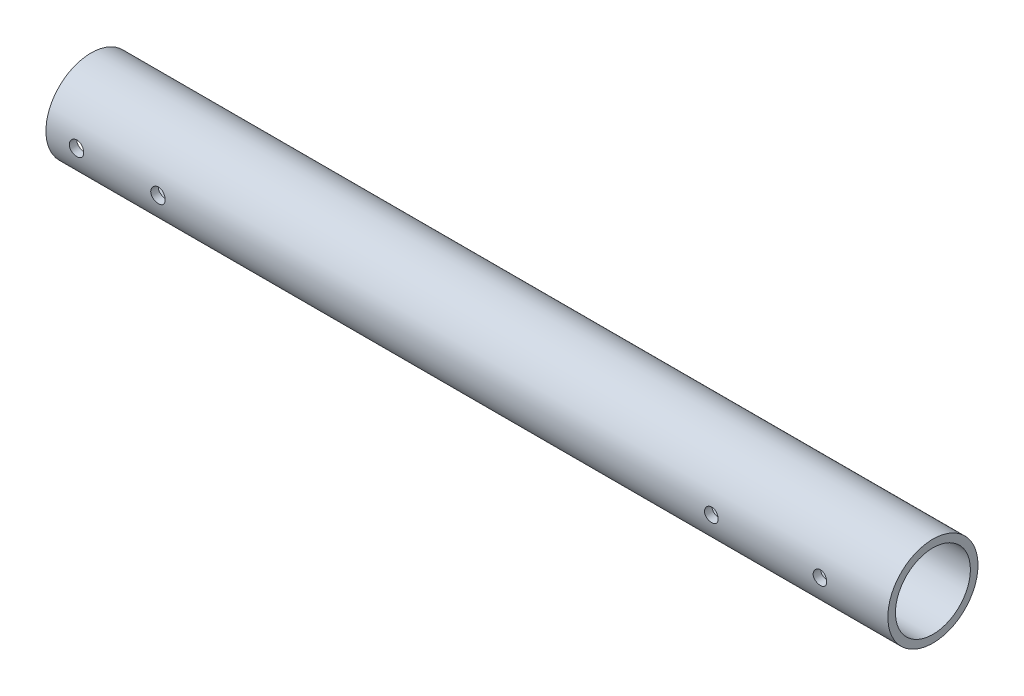
from build123d import *

# Parameters (mm, degrees)
BOSS_EXTRUDE1_DEPTH      = 196.85
BOSS_EXTRUDE1_DEPTH_BACK = 196.85
SKETCH1_R                = 21.082
SKETCH1_R_2              = 17.526
CUT_EXTRUDE1_DEPTH       = 200.095012363
CUT_EXTRUDE1_DEPTH_BACK  = 200.095012363
SKETCH2_R                = 3.3782
SKETCH3_R                = 3.175
CUT_EXTRUDE2_DEPTH       = 200.095012483


with BuildPart() as part:
    # Sketch1 → Boss-Extrude1 (new, two sides: drawn at the far end of the back side and taken through both)
    with BuildSketch(Plane(origin=(0, 0, 0), x_dir=(0, 0, -1), z_dir=(1, 0, 0)).offset(-BOSS_EXTRUDE1_DEPTH_BACK)):
        Circle(SKETCH1_R)
        Circle(SKETCH1_R_2, mode=Mode.SUBTRACT)
    extrude(amount=BOSS_EXTRUDE1_DEPTH + BOSS_EXTRUDE1_DEPTH_BACK)

    # Sketch2 → Cut-Extrude1 (cut, two sides: drawn at the far end of the back side and taken through both)
    with BuildSketch(Plane.XY.offset(-CUT_EXTRUDE1_DEPTH_BACK)):
        with Locations((-144.4625, 0)):
            Circle(SKETCH2_R)
        with Locations((-182.5625, 0)):
            Circle(SKETCH2_R)
    extrude(amount=CUT_EXTRUDE1_DEPTH + CUT_EXTRUDE1_DEPTH_BACK, mode=Mode.SUBTRACT)

    # Sketch3 → Cut-Extrude2 (cut, through all)
    with BuildSketch(Plane.XY):
        with Locations((165.1, 0)):
            Circle(SKETCH3_R)
        with Locations((114.3, 0)):
            Circle(SKETCH3_R)
    extrude(amount=CUT_EXTRUDE2_DEPTH, mode=Mode.SUBTRACT)


solid = part.part
